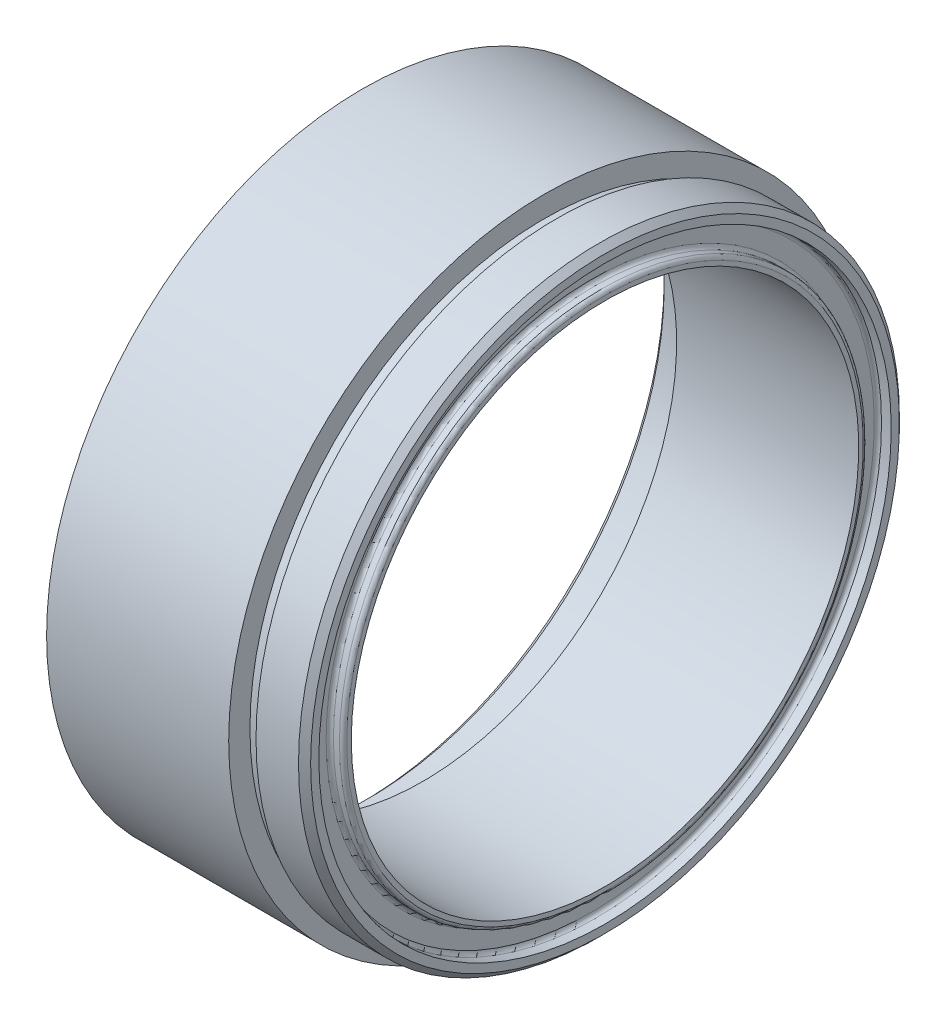
from build123d import *

# Parameters (mm, degrees)
SMUSSO1_SIZE = 0.5
RACCORDO1_R  = 0.3
SMUSSO2_SIZE = 0.5


with BuildPart() as part:
    # Schizzo1 → Rivoluzione1 (revolve)
    with BuildSketch(Plane.XY, mode=Mode.PRIVATE) as rivoluzione1_sk:
        Polygon((-5, 26), (10, 26), (10, 24.25), (11, 24.25), (11, 24.75), (15, 24.75), (15, 23.575), (13.9, 23.575), (13.9, 21.575), (15, 21.575), (15, 20.9), (0, 20.9), (0, 24.875), (-0.5, 24.875), (-0.5, 24.375), (-5, 24.375), align=None)
    revolve(rivoluzione1_sk.sketch.rotate(Axis((0, 0, 0), (1, 0, 0)), 90), axis=Axis((0, 0, 0), (1, 0, 0)))  # turned: the seam where the file's is

    # Smusso1
    smusso1_edges = [part.edges().sort_by_distance(p)[0] for p in [
        (-5, 0, -24.375),
    ]]
    chamfer(smusso1_edges, length=SMUSSO1_SIZE)

    # Raccordo1
    raccordo1_edges = [part.edges().sort_by_distance(p)[0] for p in [
        (13.9, 0, -23.575),
        (13.9, 0, -21.575),
        (15, 0, -21.575),
    ]]
    fillet(raccordo1_edges, radius=RACCORDO1_R)

    # Smusso2
    smusso2_edges = [part.edges().sort_by_distance(p)[0] for p in [
        (15, 0, -24.75),
    ]]
    chamfer(smusso2_edges, length=SMUSSO2_SIZE)


solid = part.part
